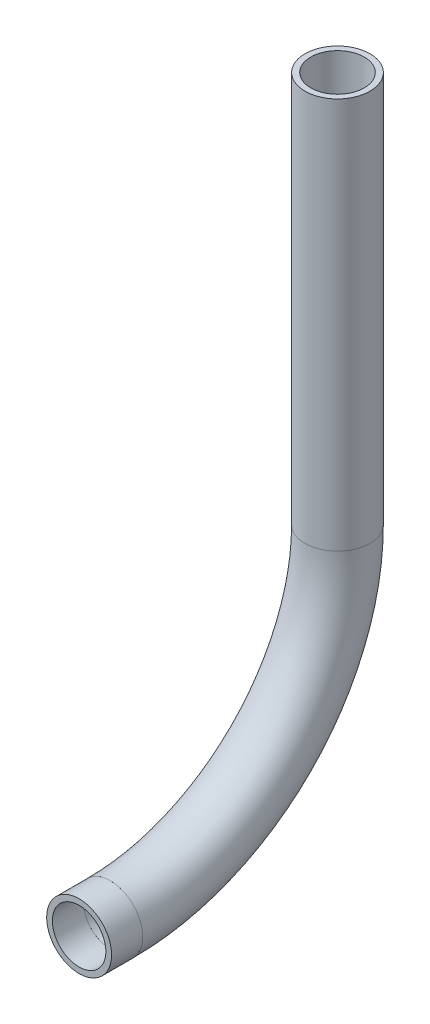
from build123d import *

# Parameters (mm, degrees)
SKETCH11_R                = 3.175
SKETCH11_R_2              = 2.6162
PIPE_0_5_SCH_40_1_DEPTH   = 3.05231551
SKETCH11_ON_SEGMENT_2_R   = 3.175
SKETCH11_ON_SEGMENT_2_R_2 = 2.6162
PIPE_0_5_SCH_40_1_2_ANGLE = 90
SKETCH11_ON_SEGMENT_3_R   = 3.175
SKETCH11_ON_SEGMENT_3_R_2 = 2.6162
PIPE_0_5_SCH_40_1_3_DEPTH = 38.312746142


with BuildPart() as part:
    # Sketch11 → Pipe 0.5 SCH 40(1) (new body)
    with BuildSketch(Plane(origin=(0, 600.034535067, 303.144625759), x_dir=(0, 1, 0), z_dir=(0, 0, -1))):
        Circle(SKETCH11_R)
        Circle(SKETCH11_R_2, mode=Mode.SUBTRACT)
    extrude(amount=PIPE_0_5_SCH_40_1_DEPTH)


with BuildPart() as body_2:
    # Sketch11 on segment 2 (carried to the start of arc 2) → Pipe 0.5 SCH 40_1 2 (revolve)
    with BuildSketch(Plane(origin=(0, 600.034535067, 300.092310249), x_dir=(0, 1, 0), z_dir=(0, 0, -1))):
        Circle(SKETCH11_ON_SEGMENT_2_R)
        Circle(SKETCH11_ON_SEGMENT_2_R_2, mode=Mode.SUBTRACT)
    revolve(axis=Axis((0, 622.259535067, 300.092310249), (1, 0, 0)), revolution_arc=PIPE_0_5_SCH_40_1_2_ANGLE)


with BuildPart() as body_3:
    # Sketch11 on segment 3 (carried to segment 3) → Pipe 0.5 SCH 40_1 3 (new body)
    with BuildSketch(Plane(origin=(0, 622.259535067, 277.867310249), x_dir=(0, 0, 1), z_dir=(0, 1, 0))):
        Circle(SKETCH11_ON_SEGMENT_3_R)
        Circle(SKETCH11_ON_SEGMENT_3_R_2, mode=Mode.SUBTRACT)
    extrude(amount=PIPE_0_5_SCH_40_1_3_DEPTH)


solid = Compound([part.part, body_2.part, body_3.part])
